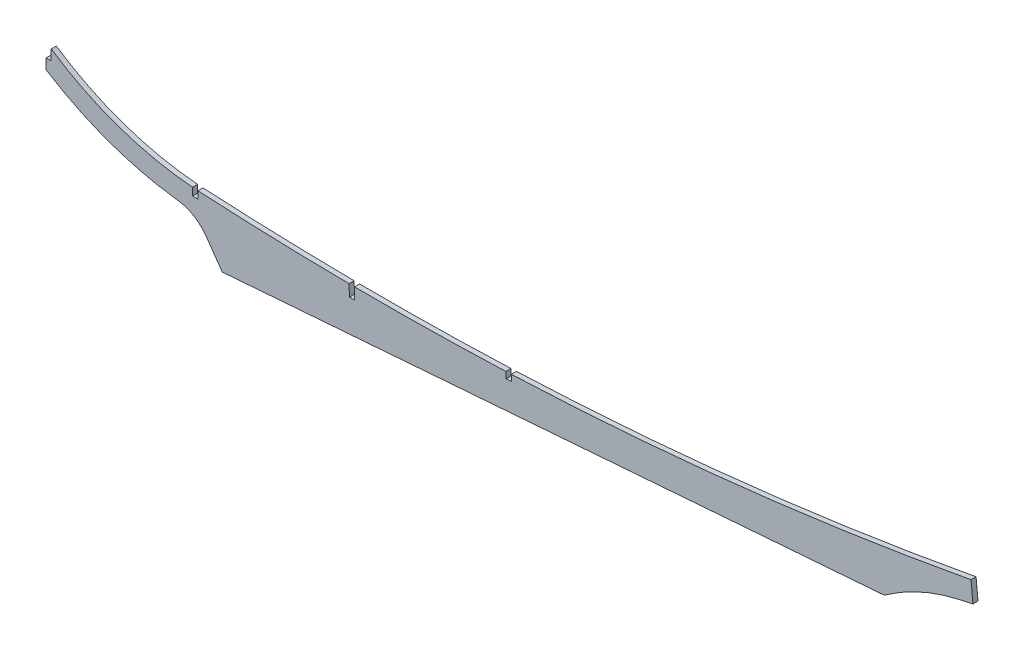
from build123d import *

# Parameters (mm, degrees)
BOSS_EXTRUDE1_DEPTH = 1.5875
FILLET1_R           = 127
FILLET2_R           = 25.4
SKETCH2_W           = 3.302
SKETCH2_H           = 12.7
SKETCH2_W_2         = 3.3782
CUT_EXTRUDE1_DEPTH  = 4.175


with BuildPart() as part:
    # Sketch1 → Boss-Extrude1 (new body, symmetric)
    with BuildSketch(Plane.XY):
        with BuildLine():
            Line((0, -97.5), (0, -91.458484162))
            Line((0, -91.458484162), (0, -84.854484162))
            Line((0, -84.854484162), (0, -82.26))
            ThreePointArc((0, -82.26), (1.897011907, -83.568972596), (3.81, -84.854484162))
            ThreePointArc((3.81, -84.854484162), (46.908813116, -106.039615985), (93.98, -115.559115329))
            ThreePointArc((93.98, -115.559115329), (339.07784145, -114.653396415), (582.298149945, -84.360596188))
            Line((582.298149945, -84.360596188), (583.523082908, -97.001384899))
            Line((583.523082908, -97.001384899), (550.289320925, -104.328123724))
            Line((550.289320925, -104.328123724), (527.710073756, -120.138282799))
            Line((527.710073756, -120.138282799), (110.986490966, -152.337740244))
            Line((110.986490966, -152.337740244), (93.98, -128.27))
            ThreePointArc((93.98, -128.27), (45.056564108, -118.790242286), (0, -97.5))
        make_face()
    extrude(amount=BOSS_EXTRUDE1_DEPTH, both=True)

    # Fillet1
    fillet1_edges = [part.edges().sort_by_distance(p)[0] for p in [
        (550.289320925, -104.328123724, -0.79375),
    ]]
    fillet(fillet1_edges, radius=FILLET1_R)

    # Fillet2
    fillet2_edges = [part.edges().sort_by_distance(p)[0] for p in [
        (93.98, -128.27, 0.79375),
    ]]
    fillet(fillet2_edges, radius=FILLET2_R)

    # Sketch2 → Cut-Extrude1 (cut, through all)
    with BuildSketch(Plane.XY.offset(1.5875)):
        with Locations((1.651, -84.72524711)):
            Rectangle(SKETCH2_W, SKETCH2_H)
        with Locations((93.98, -113.91339143)):
            Rectangle(SKETCH2_W_2, SKETCH2_H)
        Polygon((190.965218572, -126.030176605), (194.342678534, -125.959469873), (194.076863752, -113.262251969), (190.69940379, -113.332958701), align=None)
        Polygon((289.697985722, -121.153429558), (293.07306112, -121.008166691), (292.800010619, -114.664040004), (289.424935222, -114.80930287), align=None)
    extrude(amount=-CUT_EXTRUDE1_DEPTH, mode=Mode.SUBTRACT)


solid = part.part
